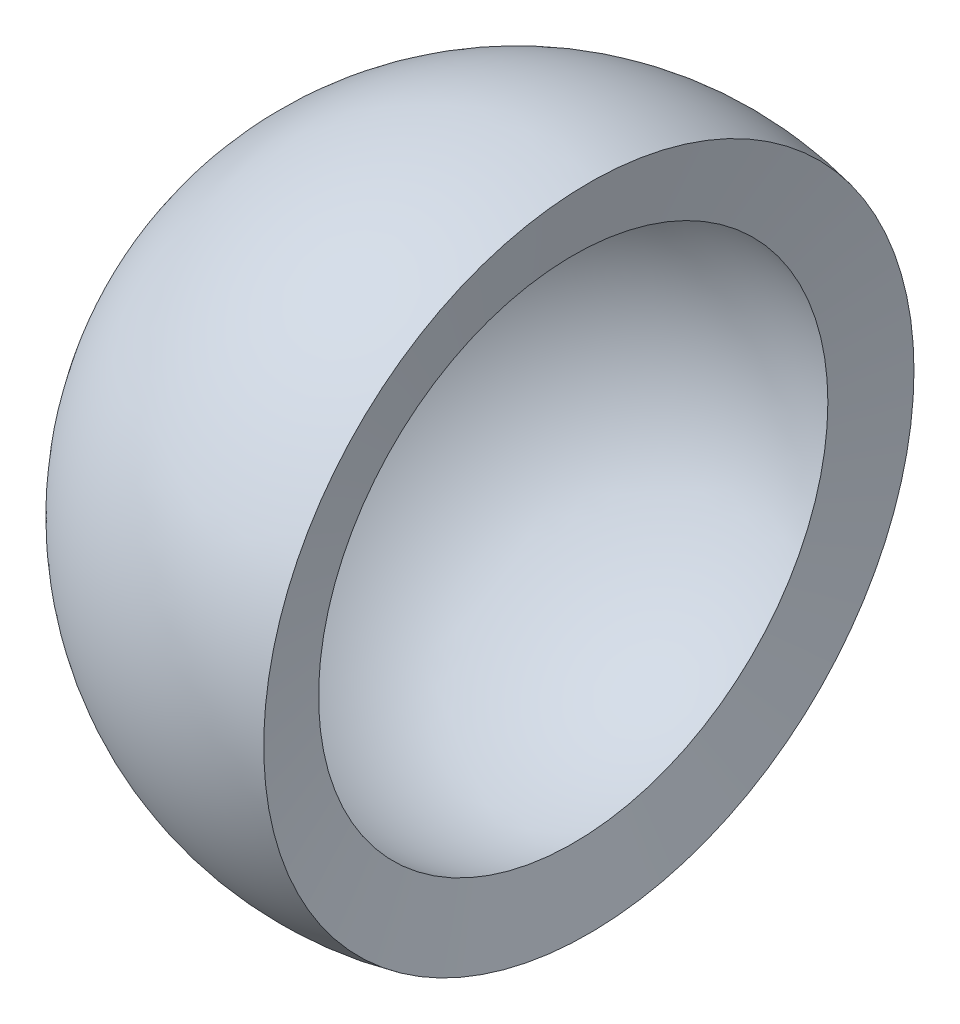
from build123d import *


with BuildPart() as part:
    # Croquis1 → Revolución1 (revolve)
    with BuildSketch(Plane(origin=(0, 0, 0), x_dir=(1, 0, 0), z_dir=(0, 1, 0))):
        with BuildLine():
            Line((-19, 0), (-24.259763925, 0))
            ThreePointArc((-24.259763925, 0), (-15.185123407, 18.919518303), (5.249853227, 23.684914751))
            Line((5.249853227, 23.684914751), (4.111631573, 18.549783983))
            ThreePointArc((4.111631573, 18.549783983), (-11.892833979, 14.817574024), (-19, 0))
        make_face()
    revolve(axis=Axis((-19, 0, 0), (-1, 0, 0)))


solid = part.part
